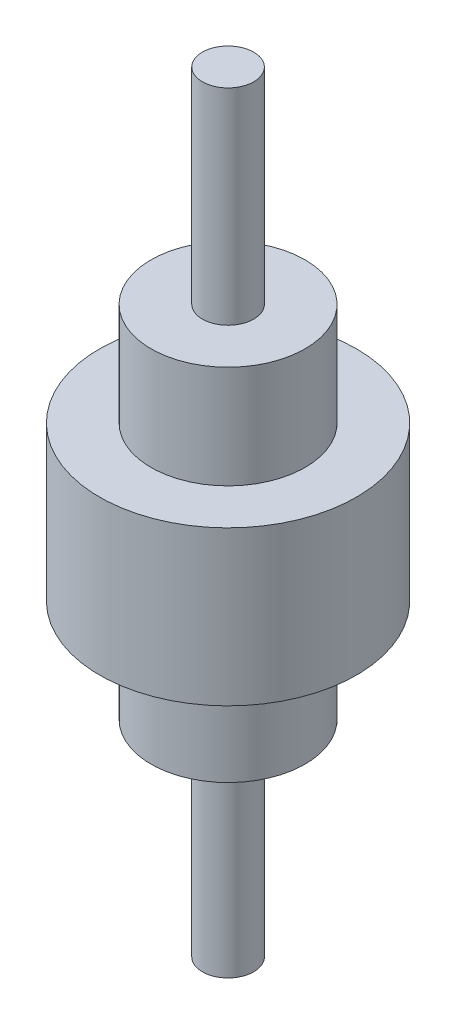
from build123d import *


with BuildPart() as part:
    # Sketch4 → Revolve4 (revolve)
    with BuildSketch(Plane.XY, mode=Mode.PRIVATE) as revolve4_sk:
        Polygon((0, 0), (100, 0), (100, 800), (300, 800), (300, 1200), (500, 1200), (500, 1800), (300, 1800), (300, 2200), (100, 2200), (100, 3000), (0, 3000), align=None)
    revolve(revolve4_sk.sketch.rotate(Axis((0, 0, 0), (0, 1, 0)), 90), axis=Axis((0, 0, 0), (0, 1, 0)))  # turned: the seam where the file's is


solid = part.part
